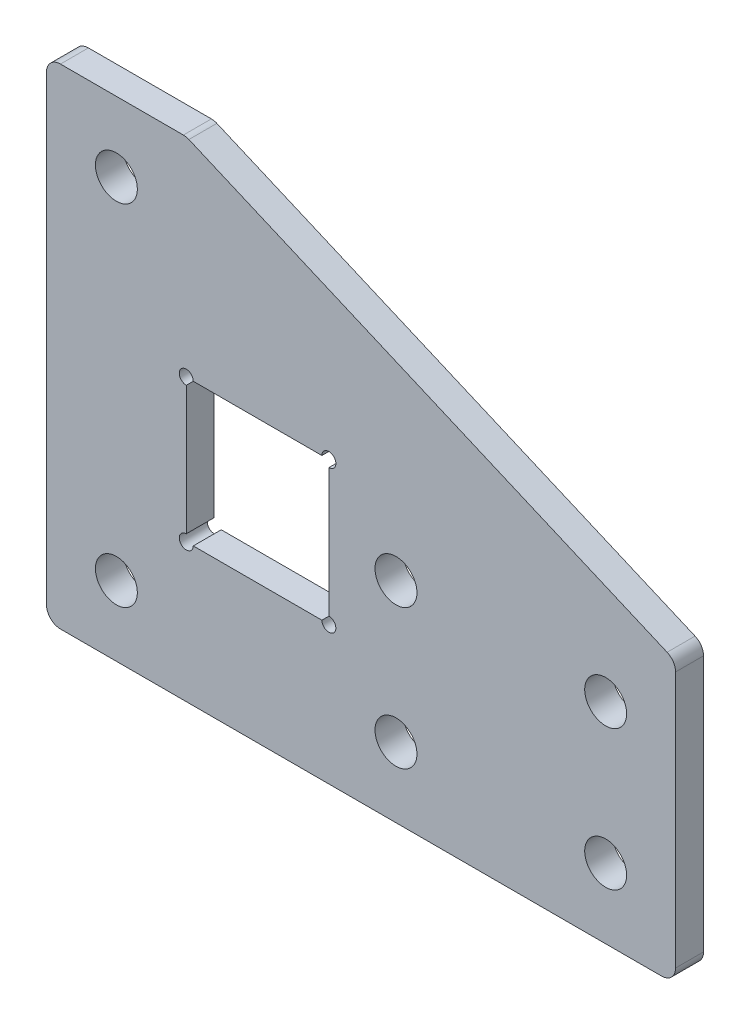
from build123d import *

# Parameters (mm, degrees)
SKETCH_1_R          = 1.5
SKETCH_1_W          = 10.2
SKETCH_1_H          = 10.2
EXTRUDE_1_DEPTH     = 2
SKETCH_2_R          = 0.5
CUT_EXTRUDE_1_DEPTH = 10
FILLET_1_R          = 1


with BuildPart() as part:
    # 草图1 → 凸台-拉伸1 (new body)
    with BuildSketch(Plane.XY):
        Polygon((5, 30), (-5, 30), (-5, -5), (40, -5), (40, 15), align=None)
        Circle(SKETCH_1_R, mode=Mode.SUBTRACT)
        with Locations((10.1, 10)):
            Rectangle(SKETCH_1_W, SKETCH_1_H, mode=Mode.SUBTRACT)
        with Locations((20, 0)):
            Circle(SKETCH_1_R, mode=Mode.SUBTRACT)
        with Locations((35, 0)):
            Circle(SKETCH_1_R, mode=Mode.SUBTRACT)
        with Locations((20, 10)):
            Circle(SKETCH_1_R, mode=Mode.SUBTRACT)
        with Locations((35, 10)):
            Circle(SKETCH_1_R, mode=Mode.SUBTRACT)
        with Locations((0, 25)):
            Circle(SKETCH_1_R, mode=Mode.SUBTRACT)
    extrude(amount=EXTRUDE_1_DEPTH)

    # 草图2 → 切除-拉伸1 (cut)
    with BuildSketch(Plane.XY.offset(2)):
        with Locations((15.2, 15.1)):
            Circle(SKETCH_2_R)
        with Locations((15.2, 4.9)):
            Circle(SKETCH_2_R)
        with Locations((5, 15.1)):
            Circle(SKETCH_2_R)
        with Locations((5, 4.9)):
            Circle(SKETCH_2_R)
    extrude(amount=-CUT_EXTRUDE_1_DEPTH, mode=Mode.SUBTRACT)

    # 圆角1
    fillet_1_edges = [part.edges().sort_by_distance(p)[0] for p in [
        (-5, 30, 1),
        (5, 30, 1),
        (40, 15, 1),
        (40, -5, 1),
        (-5, -5, 1),
    ]]
    fillet(fillet_1_edges, radius=FILLET_1_R)


solid = part.part
